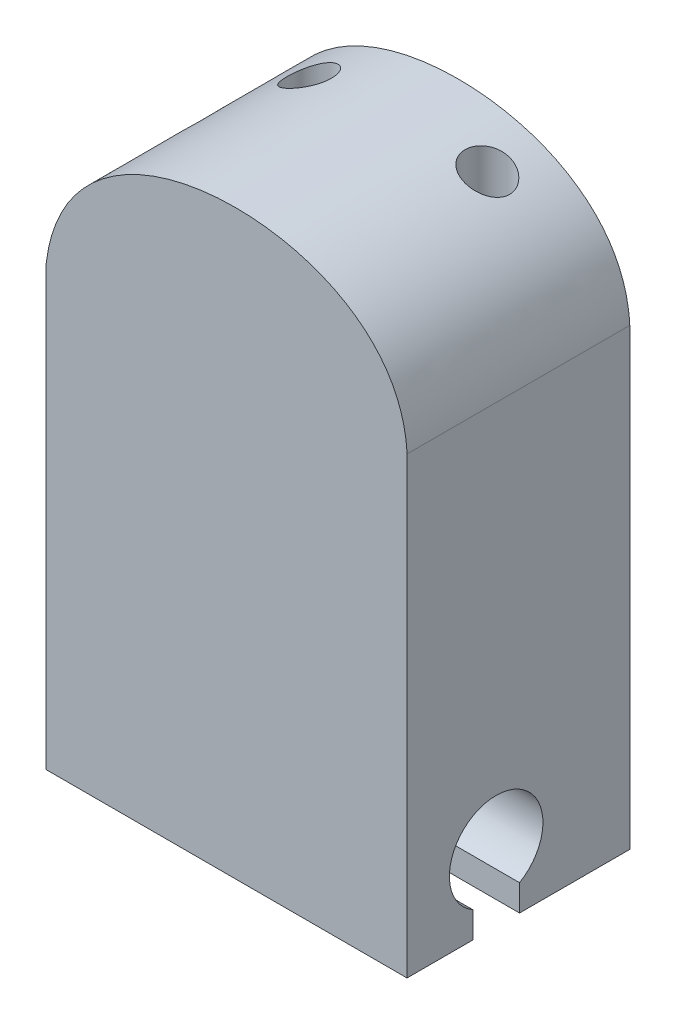
from build123d import *

# Parameters (mm, degrees)
BOSS_EXTRUDE1_DEPTH      = 10
CUT_EXTRUDE9_REACH       = 28.107
SKETCH11_R               = 1
CUT_EXTRUDE16_DEPTH      = 14.1
CUT_EXTRUDE16_DEPTH_BACK = 14.1


with BuildPart() as part:
    # Sketch1 → Boss-Extrude1 (new body)
    with BuildSketch(Plane.XY):
        with BuildLine():
            Line((-8.1, 0), (8.1, 0))
            Line((8.1, 0), (8.1, 19.7))
            Line((8.1, 19.7), (8.1, 20.376450886))
            add(Edge.make_bspline(
                [(6.48935173, 24), (7.416747291, 23.101820665), (8.022787745, 21.902680364), (8.1, 20.376450886)],
                knots=[0.795779931, 0.795779931, 0.795779931, 0.795779931, 0.974400134, 0.974400134, 0.974400134, 0.974400134], degree=3))
            Line((6.48935173, 24), (-5.856909443, 24))
            add(Edge.make_bspline(
                [(-8.1, 19.7), (-7.879513959, 21.531569286), (-7.049405333, 22.960789218), (-5.856909443, 24)],
                knots=[0, 0, 0, 0, 0.215700958, 0.215700958, 0.215700958, 0.215700958], degree=3))
            Line((-8.1, 19.7), (-8.1, 0))
        make_face()
        with BuildLine():
            add(Edge.make_bspline(
                [(-5.856909443, 24), (-4.327036412, 25.333220988), (0.13018942, 26.782367162), (4.914346008, 25.525387495), (6.48935173, 24)],
                knots=[0.215700958, 0.215700958, 0.215700958, 0.215700958, 0.492427344, 0.795779931, 0.795779931, 0.795779931, 0.795779931], degree=3))
            Line((-5.856909443, 24), (6.48935173, 24))
        make_face()
    extrude(amount=BOSS_EXTRUDE1_DEPTH)

    # Sketch11 → Cut-Extrude9 (cut, up to next)
    with BuildSketch(Plane.XZ, mode=Mode.PRIVATE) as cut_extrude9_sk1:
        with Locations((4, 2.295920755)):
            Circle(SKETCH11_R)
    cut_extrude9_tool1 = extrude(cut_extrude9_sk1.sketch, amount=-CUT_EXTRUDE9_REACH, mode=Mode.PRIVATE) & part.part
    add(cut_extrude9_tool1.solids().sort_by_distance((4, 0, 2.295921))[0], mode=Mode.SUBTRACT)
    # Sketch11 → Cut-Extrude9 (cut, up to next)
    with BuildSketch(Plane.XZ, mode=Mode.PRIVATE) as cut_extrude9_sk2:
        with Locations((-4, 2.295920755)):
            Circle(SKETCH11_R)
    cut_extrude9_tool2 = extrude(cut_extrude9_sk2.sketch, amount=-CUT_EXTRUDE9_REACH, mode=Mode.PRIVATE) & part.part
    add(cut_extrude9_tool2.solids().sort_by_distance((-4, 0, 2.295921))[0], mode=Mode.SUBTRACT)

    # Sketch14 → Cut-Extrude16 (cut, two sides)
    with BuildSketch(Plane.ZY) as cut_extrude16_sk:
        with BuildLine():
            Line((4.95, 1.181346652), (4.95, 0))
            Line((4.95, 0), (7.05, 0))
            Line((7.05, 0), (7.05, 1.181346652))
            ThreePointArc((7.05, 1.181346652), (6, 5.1), (4.95, 1.181346652))
        make_face()
    extrude(amount=CUT_EXTRUDE16_DEPTH, mode=Mode.SUBTRACT)
    extrude(cut_extrude16_sk.sketch, amount=-CUT_EXTRUDE16_DEPTH_BACK, mode=Mode.SUBTRACT)


solid = part.part
